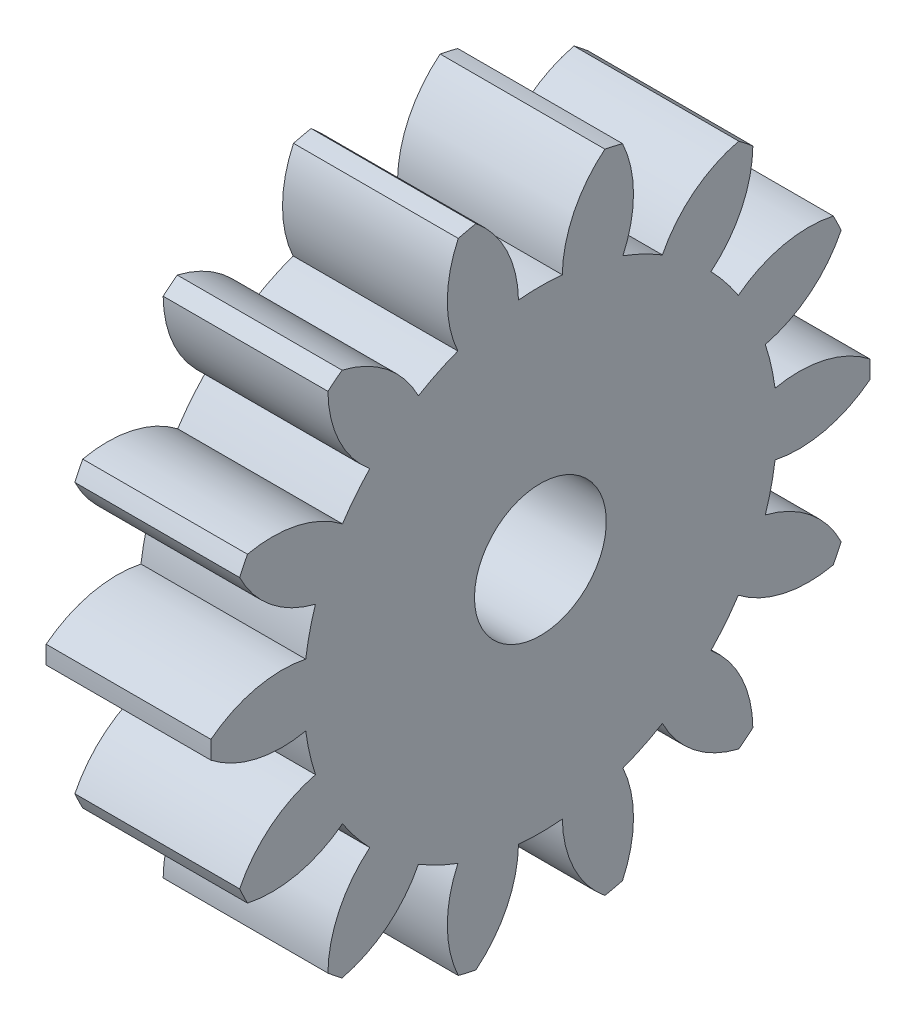
from build123d import *

# Parameters (mm, degrees)
BASPROSKE_W     = 1
BASPROSKE_H     = 2
TOOTHCUT_DEPTH  = 4
TEETHCUTS_COUNT = 14
TEETHCUTS_ANGLE = 334.285714286
BORSKE_R        = 0.4
BORE_DEPTH      = 50.0000508


with BuildPart() as part:
    # BasProSke → Base-Revolve (revolve)
    with BuildSketch(Plane(origin=(0, 0, 0), x_dir=(1, 0, 0), z_dir=(0, 1, 0)), mode=Mode.PRIVATE) as base_revolve_sk:
        with Locations((0.5, 1)):
            Rectangle(BASPROSKE_W, BASPROSKE_H)
    revolve(base_revolve_sk.sketch.rotate(Axis((-10, 0, 0), (1, 0, 0)), 180), axis=Axis((-10, 0, 0), (1, 0, 0)))

    # TooCutSke → ToothCut (cut, through all)
    with BuildSketch(Plane(origin=(0, 0, 0), x_dir=(0, 0, -1), z_dir=(1, 0, 0))):
        with BuildLine():
            ThreePointArc((0.132926628, 1.43033659), (0, 1.4365), (-0.132926628, 1.43033659))
            ThreePointArc((-0.132926628, 1.43033659), (-0.210971396, 1.739395683), (-0.417964864, 1.981804867))
            ThreePointArc((-0.417964864, 1.981804867), (0, 2.0254), (0.417964864, 1.981804867))
            ThreePointArc((0.417964864, 1.981804867), (0.210971396, 1.739395683), (0.132926628, 1.43033659))
        make_face()
    toothcut = extrude(amount=TOOTHCUT_DEPTH, mode=Mode.SUBTRACT)

    # TeethCuts: ToothCut ×14 about axis
    teethcuts_axis = Axis((-10, 0, 0), (1, 0, 0))
    for i in range(1, TEETHCUTS_COUNT):
        add(toothcut.rotate(teethcuts_axis, i * TEETHCUTS_ANGLE / (TEETHCUTS_COUNT - 1)), mode=Mode.SUBTRACT)

    # BorSke → Bore (cut, symmetric)
    with BuildSketch(Plane(origin=(0, 0, 0), x_dir=(0, 0, -1), z_dir=(1, 0, 0))):
        with Locations(Location((0, 0, 0), (0, 0, 180))):
            Circle(BORSKE_R)
    extrude(amount=BORE_DEPTH, both=True, mode=Mode.SUBTRACT)


solid = part.part
